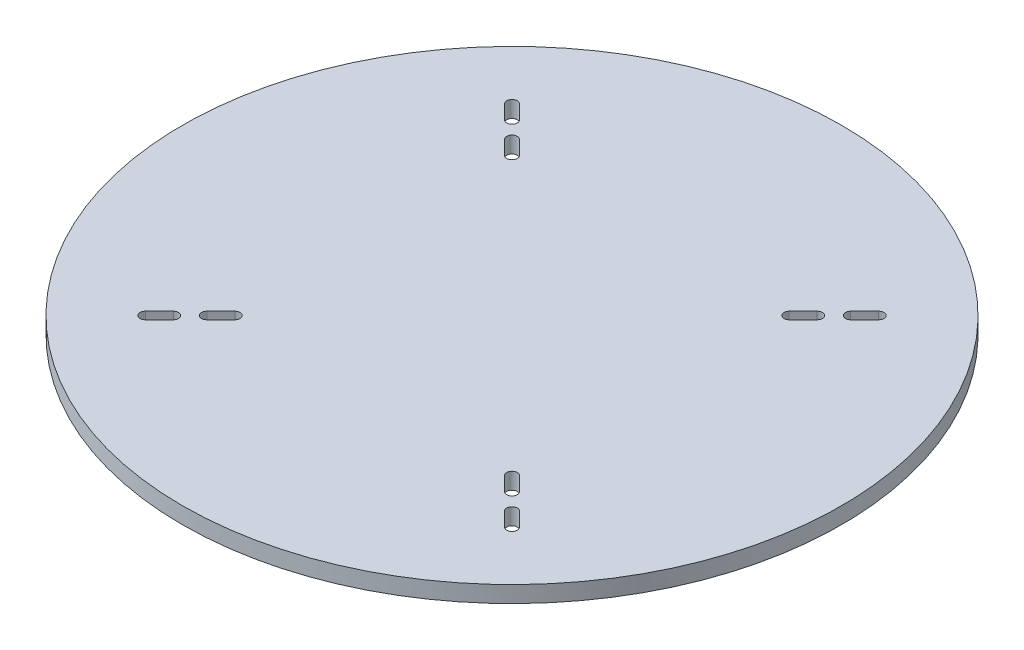
from build123d import *

# Parameters (mm, degrees)
SKETCH1_R           = 127
BOSS_EXTRUDE1_DEPTH = 6.35
CUT_EXTRUDE1_DEPTH  = 7.35


with BuildPart() as part:
    # Sketch1 → Boss-Extrude1 (new body)
    with BuildSketch(Plane(origin=(0, 0, 0), x_dir=(1, 0, 0), z_dir=(0, 1, 0))):
        Circle(SKETCH1_R)
    extrude(amount=BOSS_EXTRUDE1_DEPTH)

    # Sketch2 → Cut-Extrude1 (cut, through all)
    with BuildSketch(Plane(origin=(0, 6.35, 0), x_dir=(1, 0, 0), z_dir=(0, 1, 0))):
        with BuildLine():
            Line((-60.237491978, 57.363810019), (-54.849338305, 51.975656347))
            ThreePointArc((-54.849338305, 51.975656347), (-51.975656347, 51.975656347), (-51.975656347, 54.849338305))
            Line((-51.975656347, 54.849338305), (-57.363810019, 60.237491978))
            ThreePointArc((-57.363810019, 60.237491978), (-60.237491978, 60.237491978), (-60.237491978, 57.363810019))
        make_face()
        with BuildLine():
            ThreePointArc((54.849338305, 51.975656347), (51.975656347, 51.975656347), (51.975656347, 54.849338305))
            Line((51.975656347, 54.849338305), (57.363810019, 60.237491978))
            ThreePointArc((57.363810019, 60.237491978), (60.237491978, 60.237491978), (60.237491978, 57.363810019))
            Line((60.237491978, 57.363810019), (54.849338305, 51.975656347))
        make_face()
        with BuildLine():
            ThreePointArc((66.703276385, 63.829594426), (63.829594426, 63.829594426), (63.829594426, 66.703276385))
            Line((63.829594426, 66.703276385), (69.217748099, 72.091430058))
            ThreePointArc((69.217748099, 72.091430058), (72.091430058, 72.091430058), (72.091430058, 69.217748099))
            Line((72.091430058, 69.217748099), (66.703276385, 63.829594426))
        make_face()
        with BuildLine():
            Line((60.237491978, -57.363810019), (54.849338305, -51.975656347))
            ThreePointArc((54.849338305, -51.975656347), (51.975656347, -51.975656347), (51.975656347, -54.849338305))
            Line((51.975656347, -54.849338305), (57.363810019, -60.237491978))
            ThreePointArc((57.363810019, -60.237491978), (60.237491978, -60.237491978), (60.237491978, -57.363810019))
        make_face()
        with BuildLine():
            Line((72.091430058, -69.217748099), (66.703276385, -63.829594426))
            ThreePointArc((66.703276385, -63.829594426), (63.829594426, -63.829594426), (63.829594426, -66.703276385))
            Line((63.829594426, -66.703276385), (69.217748099, -72.091430058))
            ThreePointArc((69.217748099, -72.091430058), (72.091430058, -72.091430058), (72.091430058, -69.217748099))
        make_face()
        with BuildLine():
            ThreePointArc((-54.849338305, -51.975656347), (-51.975656347, -51.975656347), (-51.975656347, -54.849338305))
            Line((-51.975656347, -54.849338305), (-57.363810019, -60.237491978))
            ThreePointArc((-57.363810019, -60.237491978), (-60.237491978, -60.237491978), (-60.237491978, -57.363810019))
            Line((-60.237491978, -57.363810019), (-54.849338305, -51.975656347))
        make_face()
        with BuildLine():
            ThreePointArc((-66.703276385, -63.829594426), (-63.829594426, -63.829594426), (-63.829594426, -66.703276385))
            Line((-63.829594426, -66.703276385), (-69.217748099, -72.091430058))
            ThreePointArc((-69.217748099, -72.091430058), (-72.091430058, -72.091430058), (-72.091430058, -69.217748099))
            Line((-72.091430058, -69.217748099), (-66.703276385, -63.829594426))
        make_face()
        with BuildLine():
            Line((-69.217748099, 72.091430058), (-63.829594426, 66.703276385))
            ThreePointArc((-63.829594426, 66.703276385), (-63.829594426, 63.829594426), (-66.703276385, 63.829594426))
            Line((-66.703276385, 63.829594426), (-72.091430058, 69.217748099))
            ThreePointArc((-72.091430058, 69.217748099), (-72.091430058, 72.091430058), (-69.217748099, 72.091430058))
        make_face()
    extrude(amount=-CUT_EXTRUDE1_DEPTH, mode=Mode.SUBTRACT)


solid = part.part
